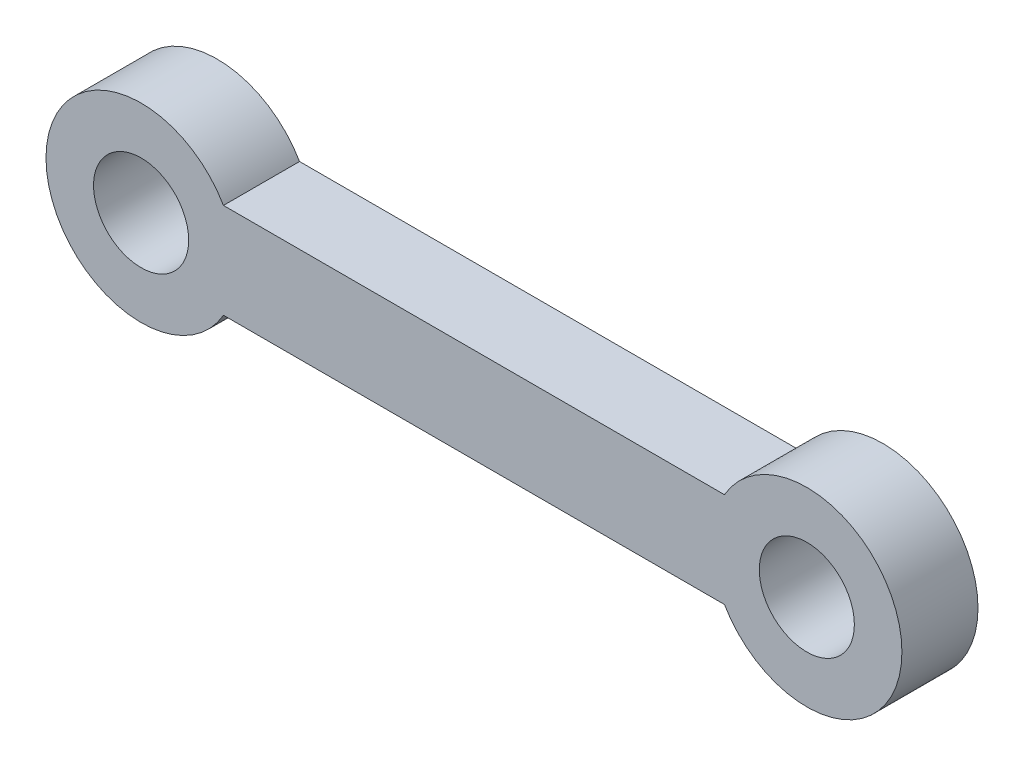
from build123d import *

# Parameters (mm, degrees)
SKETCH1_R           = 2.5
BOSS_EXTRUDE1_DEPTH = 4


with BuildPart() as part:
    # Sketch1 → Boss-Extrude1 (new body)
    with BuildSketch(Plane.XY):
        with BuildLine():
            Line((30.669872981, 2.5), (4.330127019, 2.5))
            ThreePointArc((4.330127019, 2.5), (-5, 0), (4.330127019, -2.5))
            Line((4.330127019, -2.5), (30.669872981, -2.5))
            ThreePointArc((30.669872981, -2.5), (40, 0), (30.669872981, 2.5))
        make_face()
        Circle(SKETCH1_R, mode=Mode.SUBTRACT)
        with Locations((35, 0)):
            Circle(SKETCH1_R, mode=Mode.SUBTRACT)
    extrude(amount=BOSS_EXTRUDE1_DEPTH)


solid = part.part
